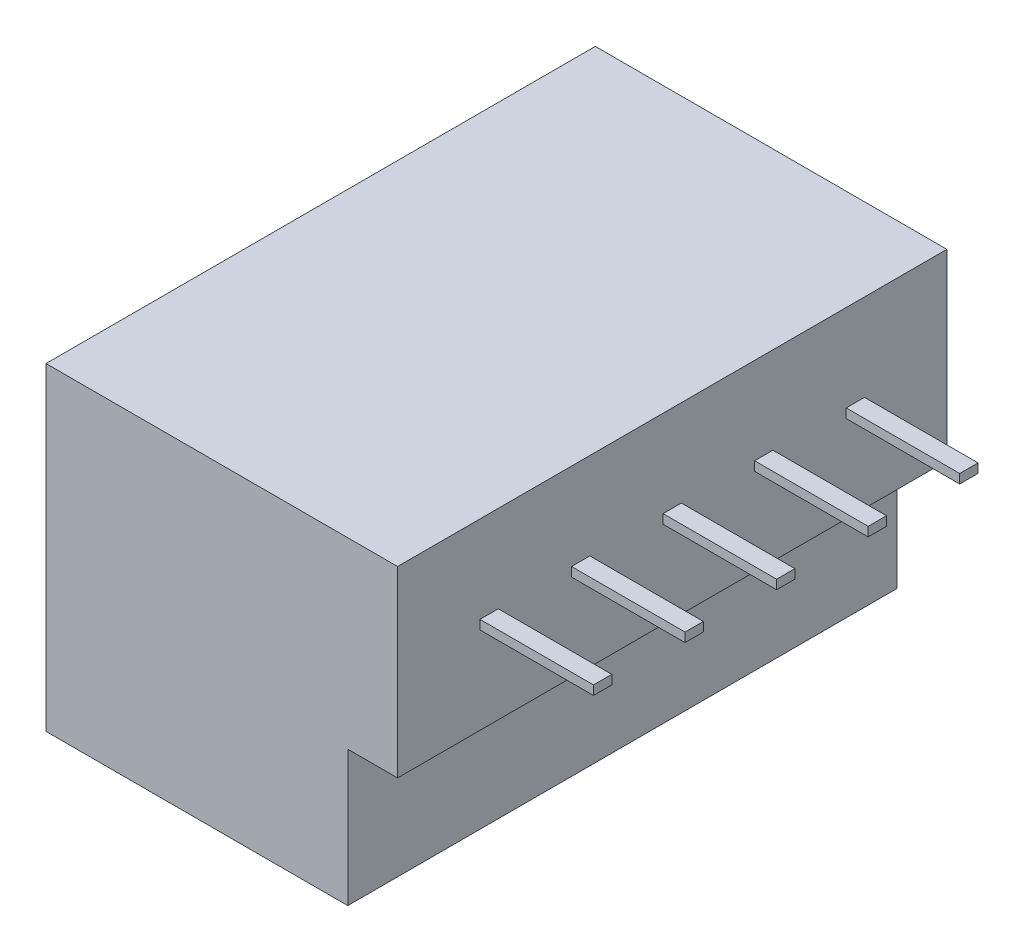
from build123d import *

# Parameters (mm, degrees)
SKETCH1_W           = 8.24
SKETCH1_H           = 15
BOSS_EXTRUDE1_DEPTH = 3.7
BOSS_EXTRUDE2_DEPTH = 5
SKETCH3_W           = 0.5
SKETCH3_H           = 0.25
BOSS_EXTRUDE3_DEPTH = 3.1


with BuildPart() as part:
    # Sketch1 → Boss-Extrude1 (new body)
    with BuildSketch(Plane(origin=(0, 0, 0), x_dir=(1, 0, 0), z_dir=(0, 1, 0))):
        with Locations((-16.236881088, -0.721940399)):
            Rectangle(SKETCH1_W, SKETCH1_H)
    extrude(amount=BOSS_EXTRUDE1_DEPTH)

    # Sketch2 → Boss-Extrude2 (add)
    with BuildSketch(Plane(origin=(0, 3.7, 0), x_dir=(1, 0, 0), z_dir=(0, 1, 0))):
        Polygon((-20.356881088, -8.221940399), (-12.116881088, -8.221940399), (-10.756881088, -8.221940399), (-10.756881088, 6.778059601), (-12.116881088, 6.778059601), (-20.356881088, 6.778059601), align=None)
    extrude(amount=BOSS_EXTRUDE2_DEPTH)

    # Sketch3 → Boss-Extrude3 (add)
    with BuildSketch(Plane(origin=(-10.756881088, 0, 0), x_dir=(0, 0, -1), z_dir=(1, 0, 0))):
        with Locations((-5.721940399, 6.2)):
            Rectangle(SKETCH3_W, SKETCH3_H)
        with Locations((-3.221940399, 6.2)):
            Rectangle(SKETCH3_W, SKETCH3_H)
        with Locations((-0.721940399, 6.2)):
            Rectangle(SKETCH3_W, SKETCH3_H)
        with Locations((1.778059601, 6.2)):
            Rectangle(SKETCH3_W, SKETCH3_H)
        with Locations((4.278059601, 6.2)):
            Rectangle(SKETCH3_W, SKETCH3_H)
    extrude(amount=BOSS_EXTRUDE3_DEPTH)


solid = part.part
